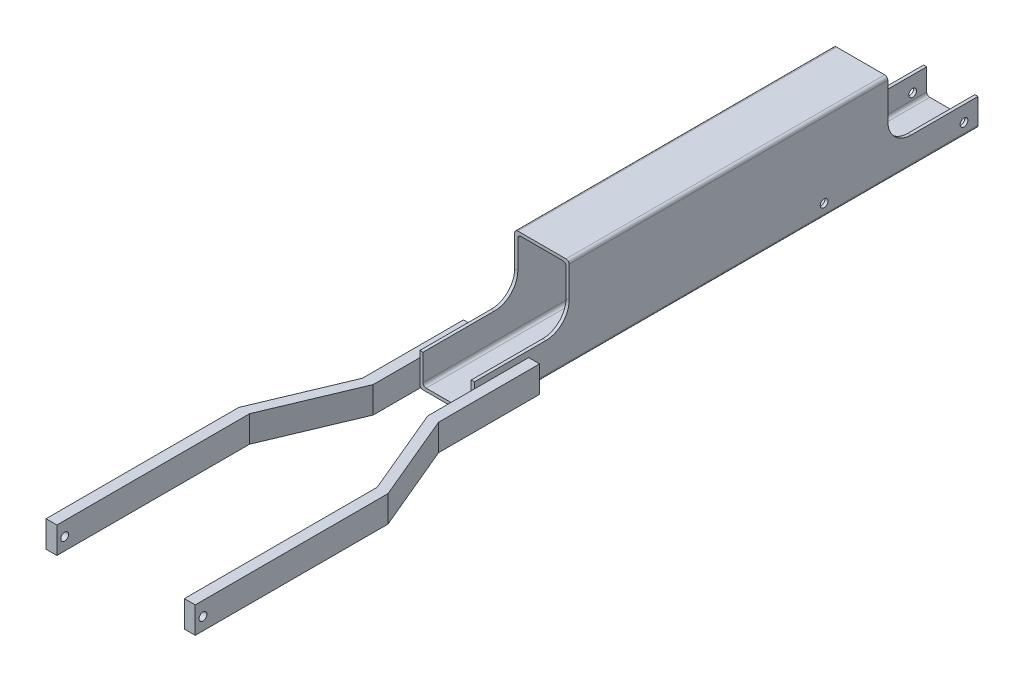
from build123d import *

# Parameters (mm, degrees)
EXTRUDE1_DEPTH = 324
SKETCH2_R      = 2.5
EXTRUDE2_DEPTH = 36
EXTRUDE3_DEPTH = 17
SKETCH4_R      = 2.5
EXTRUDE4_DEPTH = 97


with BuildPart() as part:
    # Sketch1 → Extrude1 (new body)
    with BuildSketch(Plane.XY):
        with BuildLine():
            Line((-17.939611789, -4.078161588), (13.060388211, -4.078161588))
            ThreePointArc((13.060388211, -4.078161588), (14.474601773, -4.663948025), (15.060388211, -6.078161588))
            Line((15.060388211, -6.078161588), (15.060388211, -60.078161588))
            ThreePointArc((15.060388211, -60.078161588), (14.474601773, -61.49237515), (13.060388211, -62.078161588))
            Line((13.060388211, -62.078161588), (-17.939611789, -62.078161588))
            ThreePointArc((-17.939611789, -62.078161588), (-19.353825352, -61.49237515), (-19.939611789, -60.078161588))
            Line((-19.939611789, -60.078161588), (-19.939611789, -6.078161588))
            ThreePointArc((-19.939611789, -6.078161588), (-19.353825352, -4.663948025), (-17.939611789, -4.078161588))
        make_face()
        with BuildLine():
            Line((-15.939611789, -6.078161588), (11.060388211, -6.078161588))
            ThreePointArc((11.060388211, -6.078161588), (12.474601773, -6.663948025), (13.060388211, -8.078161588))
            Line((13.060388211, -8.078161588), (13.060388211, -58.078161588))
            ThreePointArc((13.060388211, -58.078161588), (12.474601773, -59.49237515), (11.060388211, -60.078161588))
            Line((11.060388211, -60.078161588), (-15.939611789, -60.078161588))
            ThreePointArc((-15.939611789, -60.078161588), (-17.353825352, -59.49237515), (-17.939611789, -58.078161588))
            Line((-17.939611789, -58.078161588), (-17.939611789, -8.078161588))
            ThreePointArc((-17.939611789, -8.078161588), (-17.353825352, -6.663948025), (-15.939611789, -6.078161588))
        make_face(mode=Mode.SUBTRACT)
    extrude(amount=EXTRUDE1_DEPTH)

    # Sketch2 → Extrude2 (cut, through all)
    with BuildSketch(Plane(origin=(15.060388211, 0, 0), x_dir=(0, 0, -1), z_dir=(1, 0, 0))):
        with Locations((-9, -54.078161588)):
            Circle(SKETCH2_R)
        with Locations((-99, -54.078161588)):
            Circle(SKETCH2_R)
        with BuildLine():
            Line((0, -44.078161588), (-43, -44.078161588))
            ThreePointArc((-43, -44.078161588), (-53.606601718, -39.684763305), (-58, -29.078161588))
            Line((-58, -29.078161588), (-58, -4.078161588))
            Line((-58, -4.078161588), (0, -4.078161588))
            Line((0, -4.078161588), (0, -44.078161588))
        make_face()
        with BuildLine():
            Line((-324, -41.078161588), (-278, -41.078161588))
            ThreePointArc((-278, -41.078161588), (-267.393398282, -36.684763305), (-263, -26.078161588))
            Line((-263, -26.078161588), (-263, -4.078161588))
            Line((-263, -4.078161588), (-324, -4.078161588))
            Line((-324, -4.078161588), (-324, -41.078161588))
        make_face()
    extrude(amount=-EXTRUDE2_DEPTH, mode=Mode.SUBTRACT)

    # Sketch3 → Extrude3 (add)
    with BuildSketch(Plane.XZ.offset(62.078161588)):
        Polygon((15.060388211, 324), (15.060388211, 289), (22.060388211, 289), (22.060388211, 324), (22.060388211, 354), (45.560388211, 410), (45.560388211, 534), (38.560388211, 534), (38.560388211, 410), (15.060388211, 354), align=None)
        Polygon((-19.939611789, 324), (-19.939611789, 289), (-26.939611789, 289), (-26.939611789, 324), (-26.939611789, 354), (-50.439611789, 410), (-50.439611789, 534), (-43.439611789, 534), (-43.439611789, 410), (-19.939611789, 354), align=None)
    extrude(amount=-EXTRUDE3_DEPTH)

    # Sketch4 → Extrude4 (cut, through all)
    with BuildSketch(Plane(origin=(45.560388211, 0, 0), x_dir=(0, 0, -1), z_dir=(1, 0, 0))):
        with Locations((-529, -54.078161588)):
            Circle(SKETCH4_R)
    extrude(amount=-EXTRUDE4_DEPTH, mode=Mode.SUBTRACT)


solid = part.part
